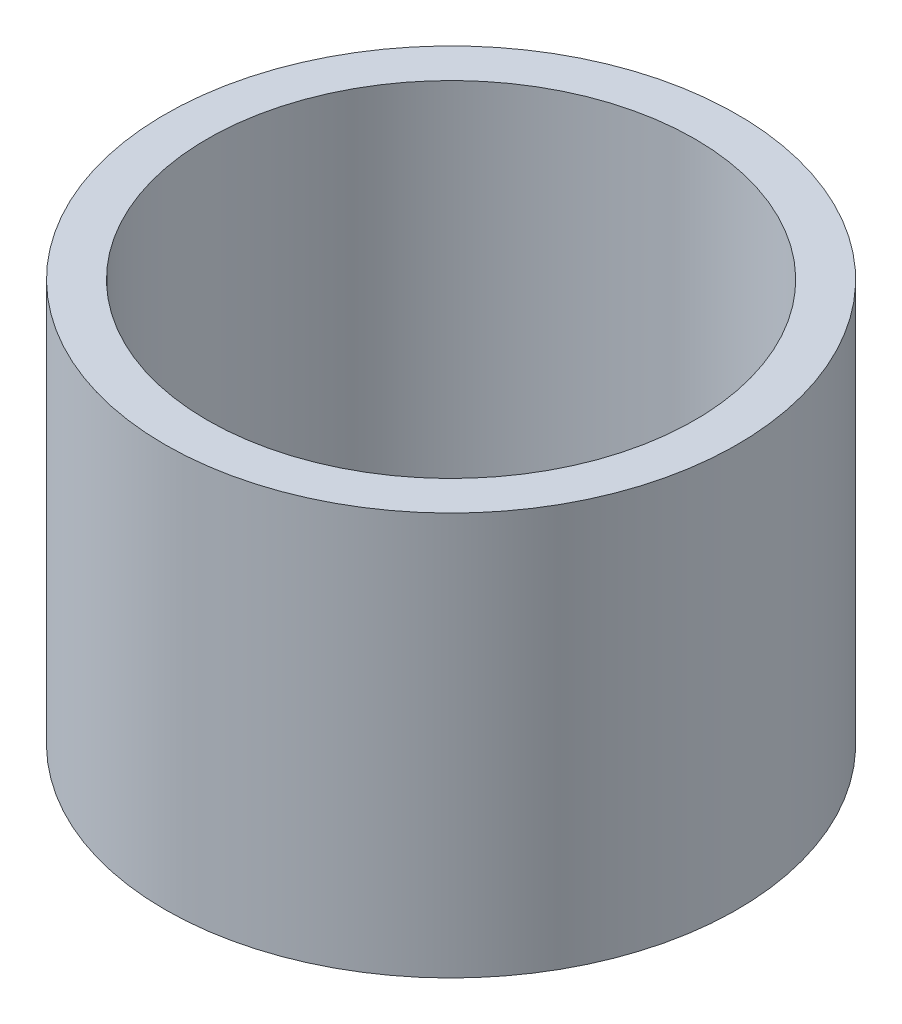
from build123d import *

# Parameters (mm, degrees)
SKETCH1_R           = 1.35
BOSS_EXTRUDE1_DEPTH = 1.9
SKETCH2_R           = 1.15
CUT_EXTRUDE1_DEPTH  = 2.9


with BuildPart() as part:
    # Sketch1 → Boss-Extrude1 (new body)
    with BuildSketch(Plane(origin=(0, 0, 0), x_dir=(1, 0, 0), z_dir=(0, 1, 0))):
        Circle(SKETCH1_R)
    extrude(amount=BOSS_EXTRUDE1_DEPTH)

    # Sketch2 → Cut-Extrude1 (cut, through all)
    with BuildSketch(Plane(origin=(0, 1.9, 0), x_dir=(1, 0, 0), z_dir=(0, 1, 0))):
        Circle(SKETCH2_R)
    extrude(amount=-CUT_EXTRUDE1_DEPTH, mode=Mode.SUBTRACT)


solid = part.part
